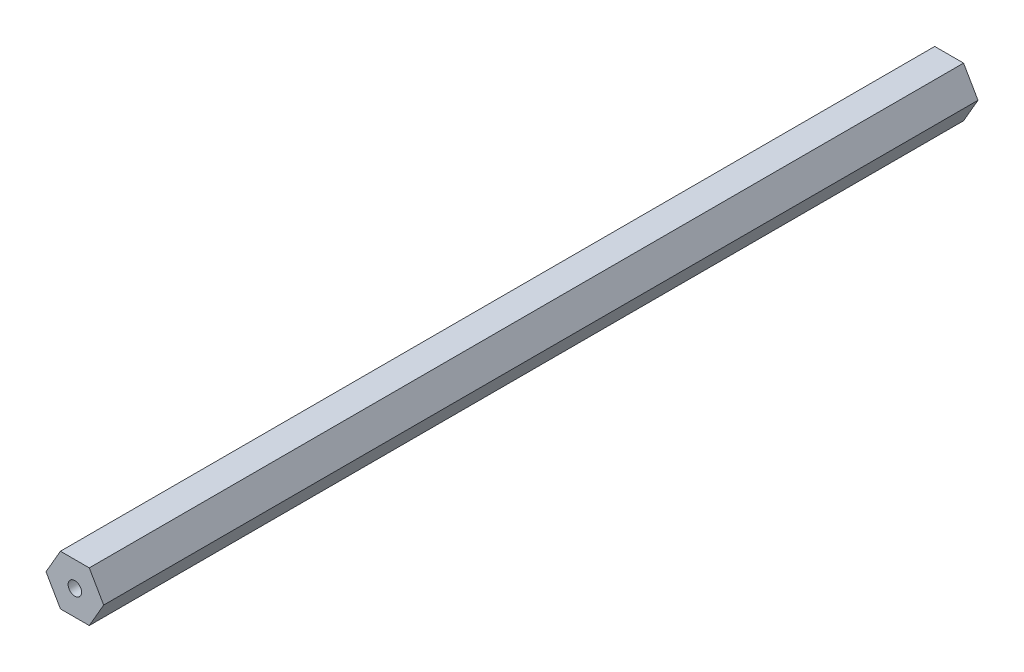
from build123d import *

# Parameters (mm, degrees)
SKETCH1_R           = 1.7145
BOSS_EXTRUDE1_DEPTH = 222.25


with BuildPart() as part:
    # Sketch1 → Boss-Extrude1 (new body)
    with BuildSketch(Plane.XY):
        Polygon((7.332348419, 0), (3.666174209, 6.35), (-3.666174209, 6.35), (-7.332348419, 0), (-3.666174209, -6.35), (3.666174209, -6.35), align=None)
        Circle(SKETCH1_R, mode=Mode.SUBTRACT)
    extrude(amount=BOSS_EXTRUDE1_DEPTH)


solid = part.part
